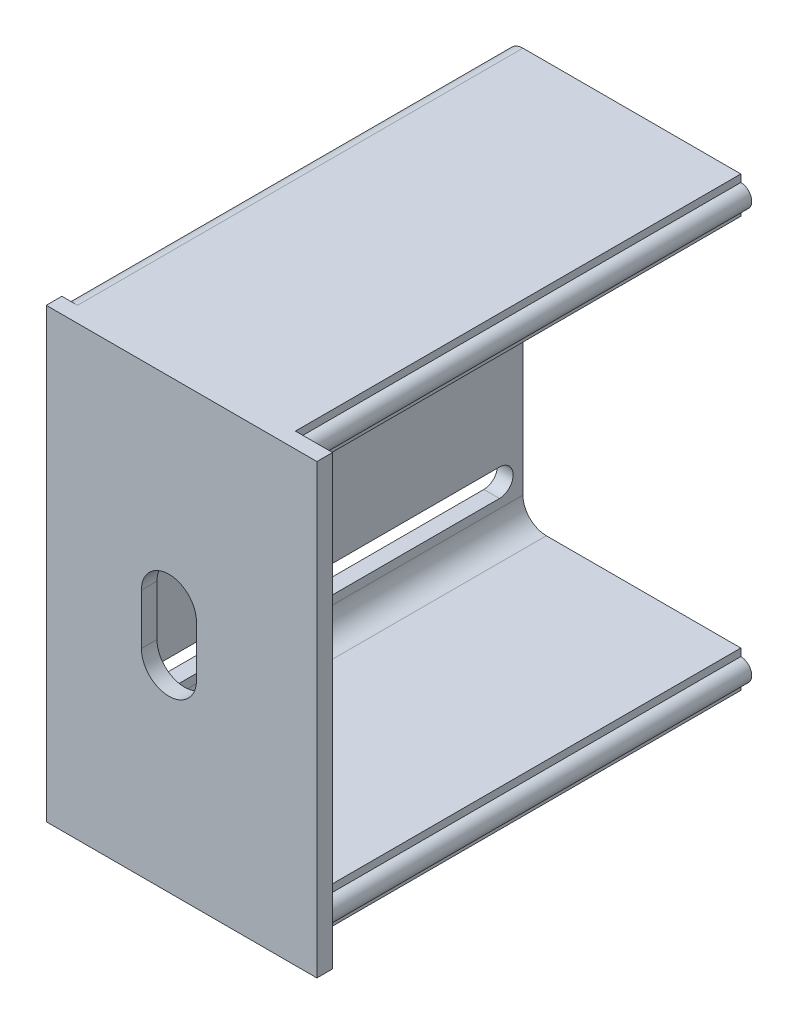
from build123d import *

# Parameters (mm, degrees)
CROQUIS1_W              = 34.637221952
CROQUIS1_H              = 57.24088581
SALIENTE_EXTRUIR1_DEPTH = 2
SALIENTE_EXTRUIR2_DEPTH = 57
CORTAR_EXTRUIR1_DEPTH   = 3
CORTAR_EXTRUIR2_DEPTH   = 6
CORTAR_EXTRUIR3_REACH   = 61


with BuildPart() as part:
    # Croquis1 → Saliente-Extruir1 (new body)
    with BuildSketch(Plane.XY):
        with Locations((-18.894886619, 25.199603339)):
            Rectangle(CROQUIS1_W, CROQUIS1_H)
    extrude(amount=SALIENTE_EXTRUIR1_DEPTH)

    # Croquis3 → Saliente-Extruir2 (add)
    with BuildSketch(Plane(origin=(0, 0, 0), x_dir=(-1, 0, 0), z_dir=(0, 0, -1))):
        with BuildLine():
            Line((6.325110646, 52.869153193), (6.325110646, 53.820046244))
            Line((6.325110646, 53.820046244), (34.213497595, 53.820046244))
            ThreePointArc((34.213497595, 53.820046244), (35.627711158, 53.234259806), (36.213497595, 51.820046244))
            Line((36.213497595, 51.820046244), (36.213497595, -1.420839566))
            ThreePointArc((36.213497595, -1.420839566), (35.627711158, -2.835053128), (34.213497595, -3.420839566))
            Line((34.213497595, -3.420839566), (6.325110646, -3.420839566))
            Line((6.325110646, -3.420839566), (6.325110646, -2.469153193))
            ThreePointArc((6.325110646, -2.469153193), (4.927851766, -1.071894313), (6.325110646, 0.325364567))
            Line((6.325110646, 0.325364567), (6.325110646, 1.27705094))
            Line((6.325110646, 1.27705094), (31.213497595, 1.27705094))
            ThreePointArc((31.213497595, 1.27705094), (33.334817939, 2.155730596), (34.213497595, 4.27705094))
            Line((34.213497595, 4.27705094), (34.213497595, 46.12294906))
            ThreePointArc((34.213497595, 46.12294906), (33.334817939, 48.244269404), (31.213497595, 49.12294906))
            Line((31.213497595, 49.12294906), (6.325110646, 49.12294906))
            Line((6.325110646, 49.12294906), (6.325110646, 50.074635433))
            ThreePointArc((6.325110646, 50.074635433), (4.927851766, 51.471894313), (6.325110646, 52.869153193))
        make_face()
    extrude(amount=SALIENTE_EXTRUIR2_DEPTH)

    # Croquis4 → Cortar-Extruir1 (cut)
    with BuildSketch(Plane.ZY.offset(36.213497595)):
        with BuildLine():
            Line((-5, 41.506708279), (-54, 41.506708279))
            ThreePointArc((-54, 41.506708279), (-55.743291721, 43.25), (-54, 44.993291721))
            Line((-54, 44.993291721), (-5, 44.993291721))
            ThreePointArc((-5, 44.993291721), (-3.256708279, 43.25), (-5, 41.506708279))
        make_face()
        with BuildLine():
            Line((-5, 8.892498399), (-54, 8.892498399))
            ThreePointArc((-54, 8.892498399), (-55.743291721, 7.149206678), (-54, 5.405914957))
            Line((-54, 5.405914957), (-5, 5.405914957))
            ThreePointArc((-5, 5.405914957), (-3.256708279, 7.149206678), (-5, 8.892498399))
        make_face()
    extrude(amount=-CORTAR_EXTRUIR1_DEPTH, mode=Mode.SUBTRACT)

    # Croquis5 → Cortar-Extruir2 (cut)
    with BuildSketch(Plane.ZY.offset(36.213497595)):
        with BuildLine():
            Line((-14.324207984, 20.89), (-14.324207984, 29.51))
            ThreePointArc((-14.324207984, 29.51), (-12.75, 31.084207984), (-11.175792016, 29.51))
            Line((-11.175792016, 29.51), (-11.175792016, 20.89))
            ThreePointArc((-11.175792016, 20.89), (-12.75, 19.315792016), (-14.324207984, 20.89))
        make_face()
    extrude(amount=-CORTAR_EXTRUIR2_DEPTH, mode=Mode.SUBTRACT)

    # Croquis6 → Cortar-Extruir3 (cut, up to next)
    with BuildSketch(Plane.XY.offset(2), mode=Mode.PRIVATE) as cortar_extruir3_sk1:
        with BuildLine():
            Line((-24.042578579, 21.866429816), (-24.042578579, 28.336921124))
            ThreePointArc((-24.042578579, 28.336921124), (-20.515431061, 31.864068642), (-16.988283544, 28.336921124))
            Line((-16.988283544, 28.336921124), (-16.988283544, 21.866429816))
            ThreePointArc((-16.988283544, 21.866429816), (-20.515431061, 18.339282299), (-24.042578579, 21.866429816))
        make_face()
    cortar_extruir3_tool1 = extrude(cortar_extruir3_sk1.sketch, amount=-CORTAR_EXTRUIR3_REACH, mode=Mode.PRIVATE) & part.part
    add(cortar_extruir3_tool1.solids().sort_by_distance((-20.515431, 25.101675, 2))[0], mode=Mode.SUBTRACT)


solid = part.part
